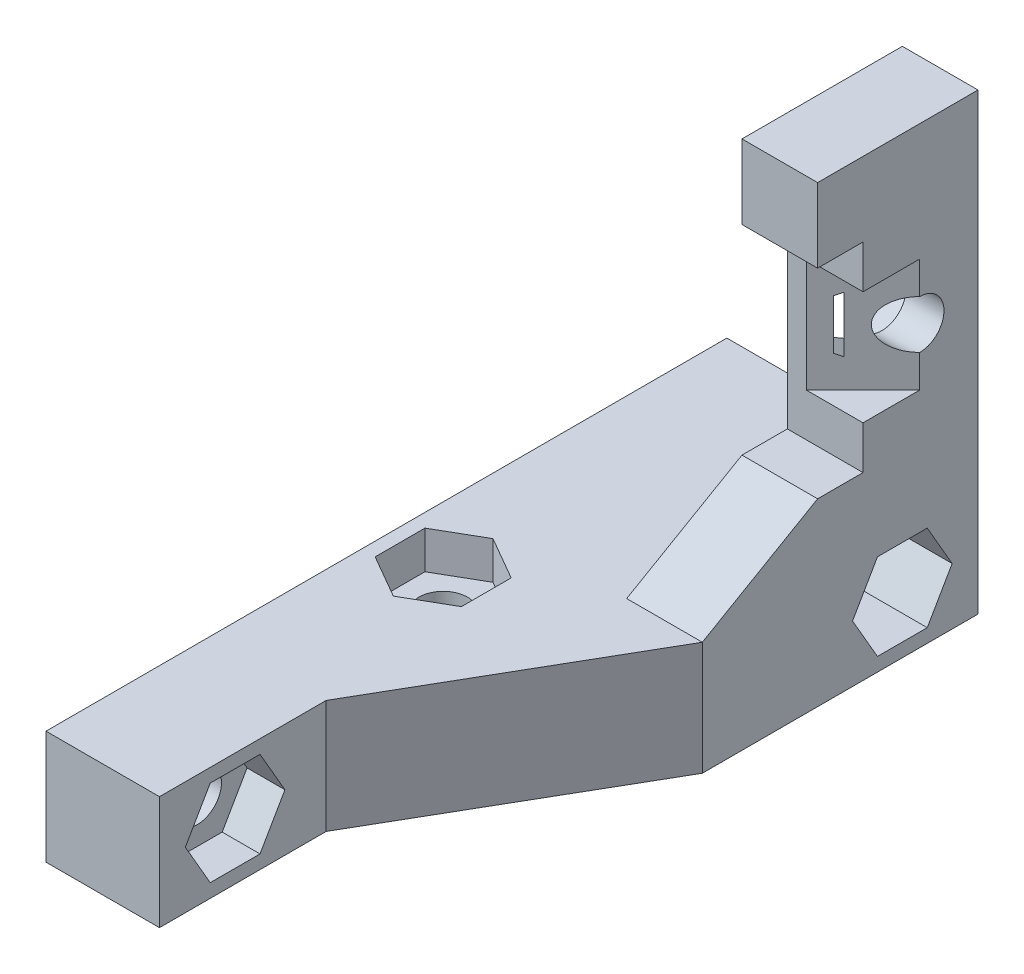
from build123d import *

# Parameters (mm, degrees)
SALIENTE_EXTRUIR1_DEPTH = 7.6
CORTAR_EXTRUIR1_REACH   = 18.6
CROQUIS2_R              = 1.6
CROQUIS3_W              = 5
CROQUIS3_H              = 4.9
SALIENTE_EXTRUIR2_DEPTH = 3
SALIENTE_EXTRUIR3_DEPTH = 5
SALIENTE_EXTRUIR4_DEPTH = 7.621024
SALIENTE_EXTRUIR5_DEPTH = 7.5
CROQUIS7_W              = 7.5
CROQUIS7_H              = 7.5
SALIENTE_EXTRUIR6_DEPTH = 26.778976
CORTAR_EXTRUIR2_REACH   = 18.6
CROQUIS8_R              = 1.6
CORTAR_EXTRUIR3_DEPTH   = 2.5
CORTAR_EXTRUIR4_DEPTH   = 2.5
CORTAR_EXTRUIR5_DEPTH   = 12.1
CORTAR_EXTRUIR6_REACH   = 9.5
CROQUIS12_R             = 1.6
CORTAR_EXTRUIR7_DEPTH   = 2.5
CORTAR_EXTRUIR8_DEPTH   = 3.75


with BuildPart() as part:
    # Croquis1 → Saliente-Extruir1 (new body)
    with BuildSketch(Plane.XY):
        Polygon((0, 0), (16.6, 0), (16.6, 30), (11.6, 30), (11.6, 7.5), (0, 7.5), align=None)
    extrude(amount=SALIENTE_EXTRUIR1_DEPTH)

    # Croquis2 → Cortar-Extruir1 (cut, up to next)
    with BuildSketch(Plane(origin=(16.6, 0, 0), x_dir=(0, 0, -1), z_dir=(1, 0, 0)), mode=Mode.PRIVATE) as cortar_extruir1_sk1:
        with Locations((-3.85, 18.5)):
            Circle(CROQUIS2_R)
    cortar_extruir1_tool1 = extrude(cortar_extruir1_sk1.sketch, amount=-CORTAR_EXTRUIR1_REACH, mode=Mode.PRIVATE) & part.part
    add(cortar_extruir1_tool1.solids().sort_by_distance((16.6, 18.5, 3.85))[0], mode=Mode.SUBTRACT)

    # Croquis3 → Saliente-Extruir2 (add)
    with BuildSketch(Plane.XY.offset(7.6)):
        with Locations((14.1, 27.55)):
            Rectangle(CROQUIS3_W, CROQUIS3_H)
        Polygon((11.6, 11.9), (16.6, 11.9), (16.6, 0), (0, 0), (0, 7.5), (11.6, 7.5), align=None)
    extrude(amount=SALIENTE_EXTRUIR2_DEPTH)

    # Croquis4 → Saliente-Extruir3 (add)
    with BuildSketch(Plane(origin=(16.6, 0, 0), x_dir=(0, 0, -1), z_dir=(1, 0, 0))):
        Polygon((-10.6, 7.5), (-18.221023553, 7.5), (-10.6, 11.9), align=None)
    extrude(amount=-SALIENTE_EXTRUIR3_DEPTH)

    # Croquis5 → Saliente-Extruir4 (add)
    with BuildSketch(Plane.XY.offset(10.6)):
        Polygon((16.6, 0), (16.6, 7.5), (11.6, 7.5), (0, 7.5), (0, 0), align=None)
    extrude(amount=SALIENTE_EXTRUIR4_DEPTH)

    # Croquis6 → Saliente-Extruir5 (add)
    with BuildSketch(Plane.XZ):
        Polygon((7.5, 18.221023553), (7.5, 33.982685902), (16.6, 18.221023553), align=None)
    extrude(amount=-SALIENTE_EXTRUIR5_DEPTH)

    # Croquis7 → Saliente-Extruir6 (add)
    with BuildSketch(Plane.XY.offset(18.221023553)):
        with Locations((3.75, 3.75)):
            Rectangle(CROQUIS7_W, CROQUIS7_H)
    extrude(amount=SALIENTE_EXTRUIR6_DEPTH)

    # Croquis8 → Cortar-Extruir2 (cut, up to next)
    with BuildSketch(Plane.ZY, mode=Mode.PRIVATE) as cortar_extruir2_sk1:
        with Locations((40, 3.75)):
            Circle(CROQUIS8_R)
    cortar_extruir2_tool1 = extrude(cortar_extruir2_sk1.sketch, amount=-CORTAR_EXTRUIR2_REACH, mode=Mode.PRIVATE) & part.part
    add(cortar_extruir2_tool1.solids().sort_by_distance((0, 3.75, 40))[0], mode=Mode.SUBTRACT)
    # Croquis8 → Cortar-Extruir2 (cut, up to next)
    with BuildSketch(Plane.ZY, mode=Mode.PRIVATE) as cortar_extruir2_sk2:
        with Locations((5, 3.75)):
            Circle(CROQUIS8_R)
    cortar_extruir2_tool2 = extrude(cortar_extruir2_sk2.sketch, amount=-CORTAR_EXTRUIR2_REACH, mode=Mode.PRIVATE) & part.part
    add(cortar_extruir2_tool2.solids().sort_by_distance((0, 3.75, 5))[0], mode=Mode.SUBTRACT)

    # Croquis9 → Cortar-Extruir3 (cut)
    with BuildSketch(Plane.ZY.offset(-11.6)):
        Polygon((1, 16.854551733), (3.85, 15.209103466), (6.7, 16.854551733), (6.7, 20.145448267), (3.85, 21.790896534), (1, 20.145448267), align=None)
    extrude(amount=-CORTAR_EXTRUIR3_DEPTH, mode=Mode.SUBTRACT)

    # Croquis10 → Cortar-Extruir4 (cut)
    with BuildSketch(Plane(origin=(7.5, 0, 0), x_dir=(0, 0, -1), z_dir=(1, 0, 0))):
        Polygon((-38.354551733, 6.6), (-41.645448267, 6.6), (-43.290896534, 3.75), (-41.645448267, 0.9), (-38.354551733, 0.9), (-36.709103466, 3.75), align=None)
    extrude(amount=-CORTAR_EXTRUIR4_DEPTH, mode=Mode.SUBTRACT)

    # Croquis11 → Cortar-Extruir5 (cut)
    with BuildSketch(Plane(origin=(16.6, 0, 0), x_dir=(0, 0, -1), z_dir=(1, 0, 0))):
        Polygon((-6.645448267, 0.9), (-3.354551733, 0.9), (-1.709103466, 3.75), (-3.354551733, 6.6), (-6.645448267, 6.6), (-8.290896534, 3.75), align=None)
    extrude(amount=-CORTAR_EXTRUIR5_DEPTH, mode=Mode.SUBTRACT)

    # Croquis12 → Cortar-Extruir6 (cut, up to next)
    with BuildSketch(Plane(origin=(0, 7.5, 0), x_dir=(1, 0, 0), z_dir=(0, 1, 0)), mode=Mode.PRIVATE) as cortar_extruir6_sk1:
        with Locations((3.75, -22.5)):
            Circle(CROQUIS12_R)
    cortar_extruir6_tool1 = extrude(cortar_extruir6_sk1.sketch, amount=-CORTAR_EXTRUIR6_REACH, mode=Mode.PRIVATE) & part.part
    add(cortar_extruir6_tool1.solids().sort_by_distance((3.75, 7.5, 22.5))[0], mode=Mode.SUBTRACT)

    # Croquis13 → Cortar-Extruir7 (cut)
    with BuildSketch(Plane.XZ.offset(-7.5)):
        Polygon((6.6, 20.854551733), (6.6, 24.145448267), (3.75, 25.790896534), (0.9, 24.145448267), (0.9, 20.854551733), (3.75, 19.209103466), align=None)
    extrude(amount=CORTAR_EXTRUIR7_DEPTH, mode=Mode.SUBTRACT)

    # Croquis14 → Cortar-Extruir8 (cut, symmetric)
    with BuildSketch(Plane(origin=(0, 18.5, 0), x_dir=(-1, 0, 0), z_dir=(0, 1, 0))):
        Polygon((-16.6, 7.6), (-16.6, 3.85), (-12.85, 7.6), align=None)
    extrude(amount=CORTAR_EXTRUIR8_DEPTH, both=True, mode=Mode.SUBTRACT)


solid = part.part
